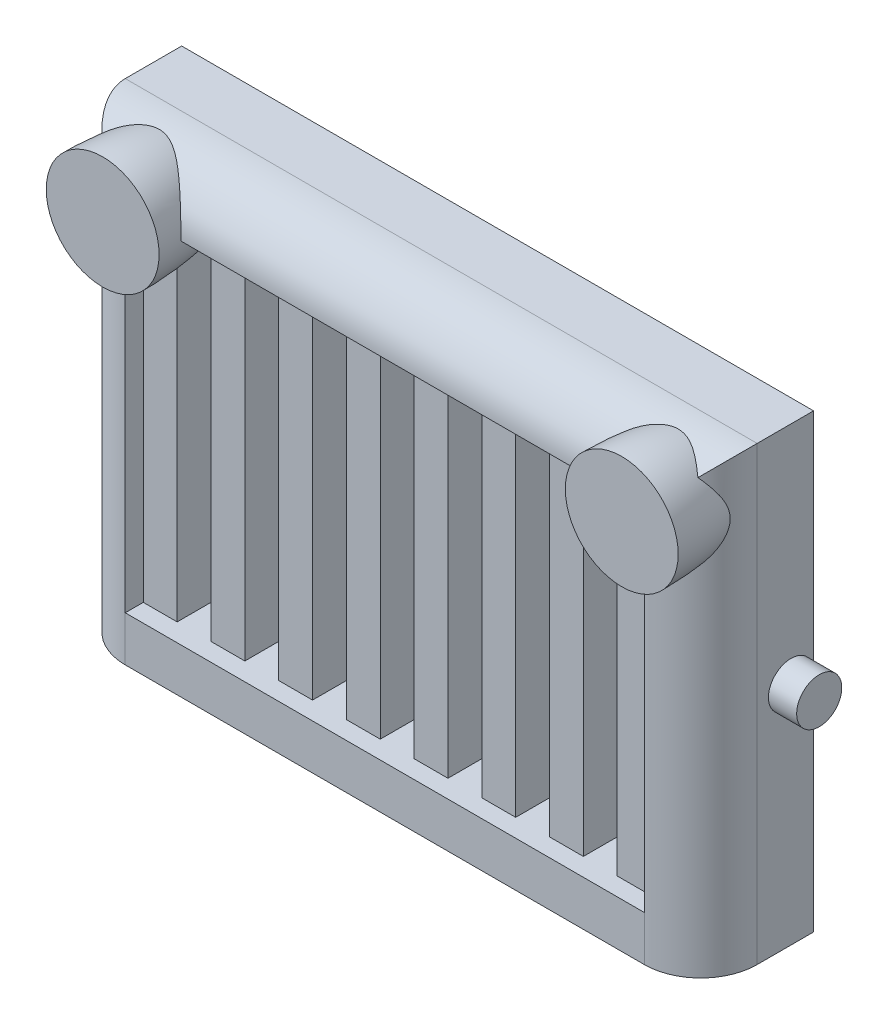
from build123d import *

# Parameters (mm, degrees)
SKETCH2_W           = 71.12
SKETCH2_H           = 50.8
BOSS_EXTRUDE1_DEPTH = 12.7
FILLET2_R           = 6.35
SKETCH3_W           = 58.42
SKETCH3_H           = 39.37
CUT_EXTRUDE1_DEPTH  = 6.35
SKETCH4_W           = 3.81
SKETCH4_H           = 39.37
BOSS_EXTRUDE2_DEPTH = 4.318
LPATTERN1_COUNT     = 8
LPATTERN1_PITCH     = 7.62
SKETCH9_W           = 68.58
SKETCH9_H           = 12.7
CUT_EXTRUDE3_DEPTH  = 5.08
SKETCH10_R          = 2.54
BOSS_EXTRUDE3_DEPTH = 3.175
SKETCH8_W           = 30.144024865
SKETCH8_H           = 52.725935383
CUT_EXTRUDE2_DEPTH  = 83.82


with BuildPart() as part:
    # Sketch2 → Boss-Extrude1 (new body)
    with BuildSketch(Plane.XY):
        with Locations((35.56, 25.4)):
            Rectangle(SKETCH2_W, SKETCH2_H)
    extrude(amount=BOSS_EXTRUDE1_DEPTH)

    # Fillet2
    fillet2_edges = [part.edges().sort_by_distance(p)[0] for p in [
        (71.12, 25.4, 12.7),
        (35.56, 50.8, 12.7),
        (0, 25.4, 12.7),
    ]]
    fillet(fillet2_edges, radius=FILLET2_R)

    # Sketch3 → Cut-Extrude1 (cut)
    with BuildSketch(Plane.XY.offset(12.7)):
        with Locations((35.56, 24.765)):
            Rectangle(SKETCH3_W, SKETCH3_H)
    extrude(amount=-CUT_EXTRUDE1_DEPTH, mode=Mode.SUBTRACT)

    # Sketch4 → Boss-Extrude2 (add)
    with BuildSketch(Plane.XY.offset(6.35)):
        with Locations((8.255, 24.765)):
            Rectangle(SKETCH4_W, SKETCH4_H)
    boss_extrude2 = extrude(amount=BOSS_EXTRUDE2_DEPTH)

    # LPattern1: Boss-Extrude2 ×8
    with Locations(*[(i * LPATTERN1_PITCH, 0, 0) for i in range(1, LPATTERN1_COUNT)]):
        add(boss_extrude2)

    # Sketch7 → Revolve1 (revolve)
    with BuildSketch(Plane(origin=(6.35, 0, 0), x_dir=(0, 0, -1), z_dir=(1, 0, 0))):
        with BuildLine():
            Line((6.218866466, 44.45), (-15.24, 44.45))
            Line((-15.24, 44.45), (-15.24, 50.8))
            ThreePointArc((-15.24, 50.8), (-4.050658531, 49.179190459), (6.218866466, 44.45))
        make_face()
    revolve1 = revolve(axis=Axis((6.35, 44.45, -6.218866466), (0, 0, 1)))

    # Sketch9 → Cut-Extrude3 (cut)
    with BuildSketch(Plane(origin=(0, 0, 0), x_dir=(-1, 0, 0), z_dir=(0, 0, -1))):
        with Locations((-35.56, 9.525)):
            Rectangle(SKETCH9_W, SKETCH9_H)
    extrude(amount=-CUT_EXTRUDE3_DEPTH, mode=Mode.SUBTRACT)

    # Sketch10 → Boss-Extrude3 (add)
    with BuildSketch(Plane.ZY):
        with Locations((2.54, 25.4)):
            Circle(SKETCH10_R)
    boss_extrude3 = extrude(amount=BOSS_EXTRUDE3_DEPTH)

    # Mirror1: Revolve1, Boss-Extrude3 across plane
    add(revolve1.mirror(Plane(origin=(35.56, 0, 0), x_dir=(0, 0, 1), z_dir=(1, 0, 0))))
    add(boss_extrude3.mirror(Plane(origin=(35.56, 0, 0), x_dir=(0, 0, 1), z_dir=(1, 0, 0))))

    # Sketch8 → Cut-Extrude2 (cut)
    with BuildSketch(Plane.ZY):
        with Locations((-15.072012433, 24.437032309)):
            Rectangle(SKETCH8_W, SKETCH8_H)
    extrude(amount=-CUT_EXTRUDE2_DEPTH, mode=Mode.SUBTRACT)


solid = part.part
